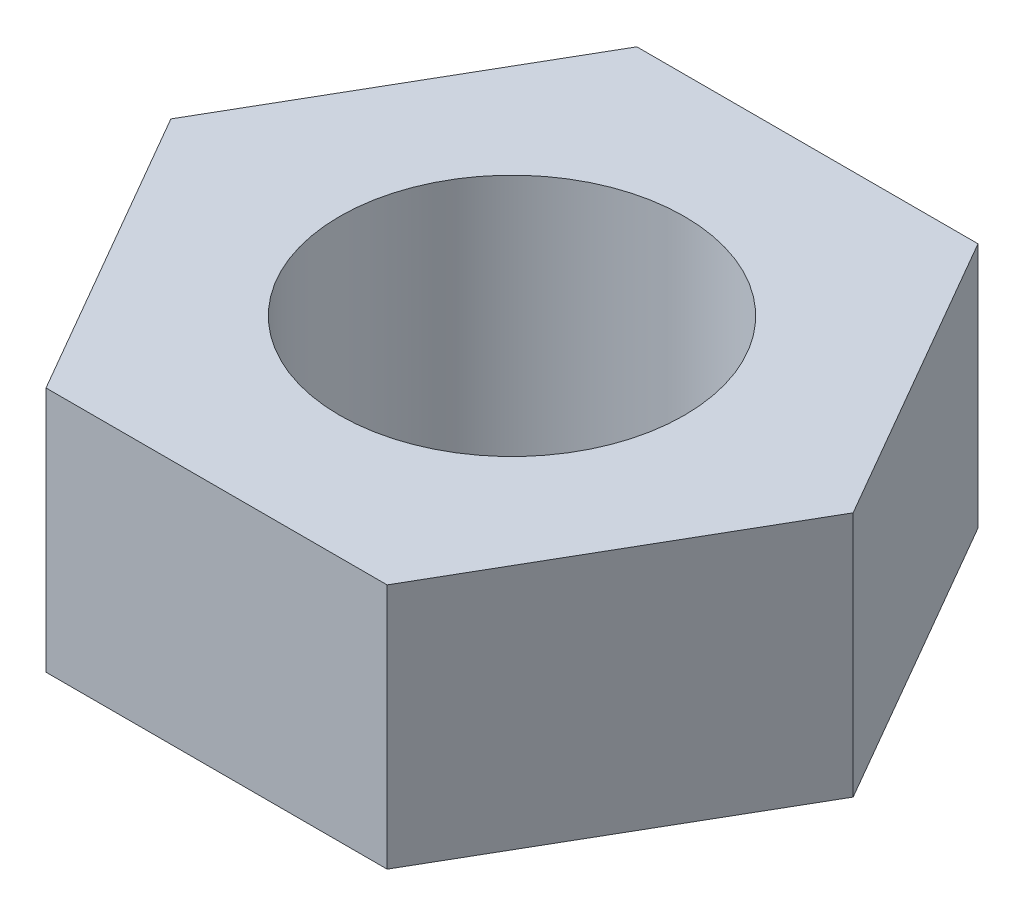
from build123d import *

# Parameters (mm, degrees)
SKETCH2_R           = 7
BOSS_EXTRUDE1_DEPTH = 10


with BuildPart() as part:
    # Sketch2 → Boss-Extrude1 (new body)
    with BuildSketch(Plane(origin=(0, 0, 0), x_dir=(1, 0, 0), z_dir=(0, 1, 0))):
        Polygon((6.92820323, 12), (-6.92820323, 12), (-13.856406461, 0), (-6.92820323, -12), (6.92820323, -12), (13.856406461, 0), align=None)
        Circle(SKETCH2_R, mode=Mode.SUBTRACT)
    extrude(amount=BOSS_EXTRUDE1_DEPTH)


solid = part.part
